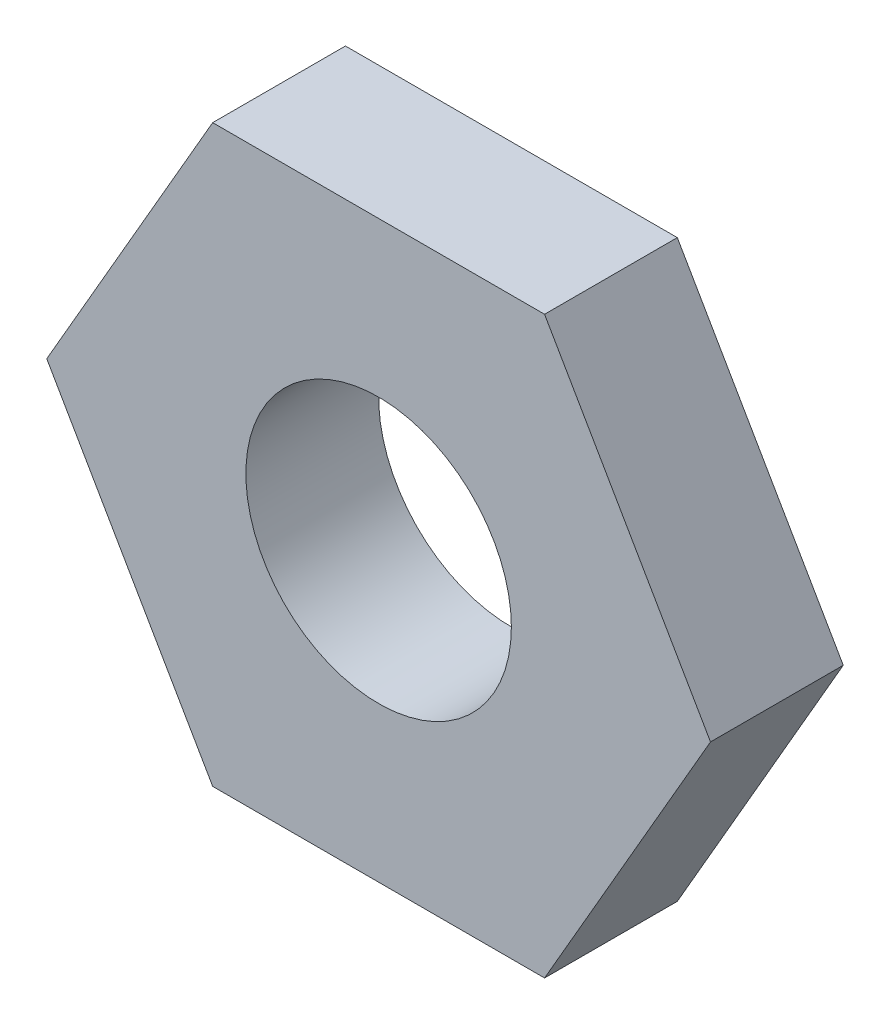
from build123d import *

# Parameters (mm, degrees)
BOSS_EXTRUDE1_DEPTH = 4
SKETCH2_R           = 4
CUT_EXTRUDE1_DEPTH  = 5


with BuildPart() as part:
    # Sketch1 → Boss-Extrude1 (new body)
    with BuildSketch(Plane.XY):
        Polygon((-10, 0), (-5, -8.660254038), (5, -8.660254038), (10, 0), (5, 8.660254038), (-5, 8.660254038), align=None)
    extrude(amount=BOSS_EXTRUDE1_DEPTH)

    # Sketch2 → Cut-Extrude1 (cut, through all)
    with BuildSketch(Plane.XY.offset(4)):
        Circle(SKETCH2_R)
    extrude(amount=-CUT_EXTRUDE1_DEPTH, mode=Mode.SUBTRACT)


solid = part.part
